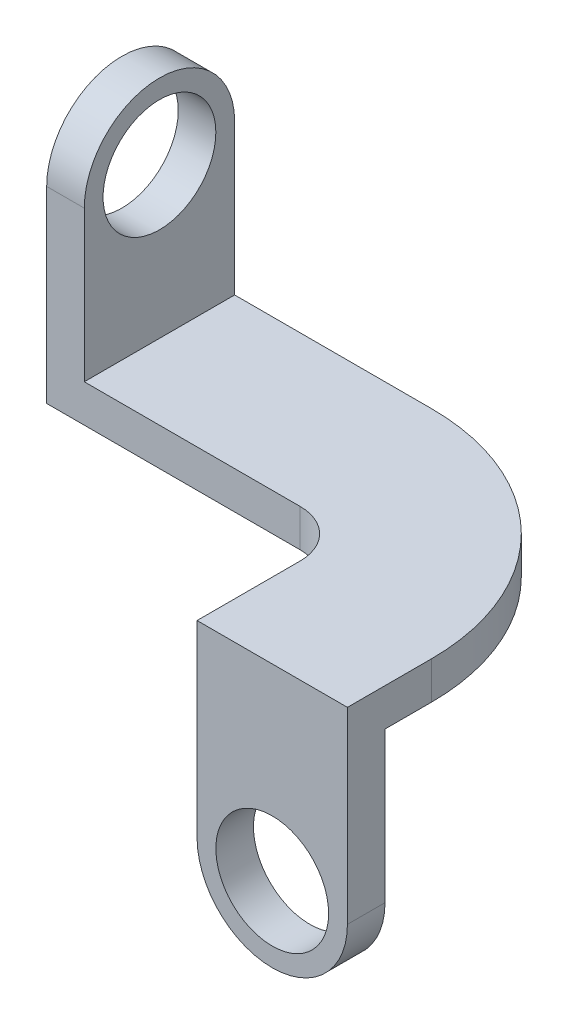
from build123d import *

# Parameters (mm, degrees)
SALIENTE_EXTRUIR1_DEPTH = 25.4
CROQUIS2_W              = 101.6
CROQUIS2_H              = 25.4
SALIENTE_EXTRUIR2_DEPTH = 101.6
CROQUIS3_R              = 50.8
SALIENTE_EXTRUIR3_DEPTH = 25.4
CROQUIS4_R              = 38.1
CORTAR_EXTRUIR1_DEPTH   = 204.2
CROQUIS5_W              = 25.4
CROQUIS5_H              = 101.6
SALIENTE_EXTRUIR4_DEPTH = 101.6
CROQUIS6_R              = 50.8
SALIENTE_EXTRUIR5_DEPTH = 25.4
CROQUIS7_R              = 38.1
CORTAR_EXTRUIR3_DEPTH   = 26.4


with BuildPart() as part:
    # Croquis1 → Saliente-Extruir1 (new body)
    with BuildSketch(Plane(origin=(0, 0, 0), x_dir=(1, 0, 0), z_dir=(0, 1, 0))):
        with BuildLine():
            Line((0, 0), (0, 101.6))
            Line((0, 101.6), (158.496, 101.6))
            ThreePointArc((158.496, 101.6), (261.948550515, 58.748550515), (304.8, -44.704))
            Line((304.8, -44.704), (304.8, -101.6))
            Line((304.8, -101.6), (203.2, -101.6))
            Line((203.2, -101.6), (203.2, -32.004))
            ThreePointArc((203.2, -32.004), (193.826245425, -9.373754575), (171.196, 0))
            Line((171.196, 0), (0, 0))
        make_face()
    extrude(amount=SALIENTE_EXTRUIR1_DEPTH)

    # Croquis2 → Saliente-Extruir2 (add)
    with BuildSketch(Plane.XZ):
        with Locations((254, 88.9)):
            Rectangle(CROQUIS2_W, CROQUIS2_H)
    extrude(amount=SALIENTE_EXTRUIR2_DEPTH)

    # Croquis3 → Saliente-Extruir3 (add)
    with BuildSketch(Plane.XY.offset(101.6)):
        with Locations((254, -101.6)):
            Circle(CROQUIS3_R)
    extrude(amount=-SALIENTE_EXTRUIR3_DEPTH)

    # Croquis4 → Cortar-Extruir1 (cut, through all)
    with BuildSketch(Plane.XY.offset(101.6)):
        with Locations((254, -101.6)):
            Circle(CROQUIS4_R)
    extrude(amount=-CORTAR_EXTRUIR1_DEPTH, mode=Mode.SUBTRACT)

    # Croquis5 → Saliente-Extruir4 (add)
    with BuildSketch(Plane(origin=(0, 25.4, 0), x_dir=(1, 0, 0), z_dir=(0, 1, 0))):
        with Locations((12.7, 50.8)):
            Rectangle(CROQUIS5_W, CROQUIS5_H)
    extrude(amount=SALIENTE_EXTRUIR4_DEPTH)

    # Croquis6 → Saliente-Extruir5 (add)
    with BuildSketch(Plane(origin=(25.4, 0, 0), x_dir=(0, 0, -1), z_dir=(1, 0, 0))):
        with Locations((50.8, 127)):
            Circle(CROQUIS6_R)
    extrude(amount=-SALIENTE_EXTRUIR5_DEPTH)

    # Croquis7 → Cortar-Extruir3 (cut, through all)
    with BuildSketch(Plane(origin=(25.4, 0, 0), x_dir=(0, 0, -1), z_dir=(1, 0, 0))):
        with Locations((50.8, 127)):
            Circle(CROQUIS7_R)
    extrude(amount=-CORTAR_EXTRUIR3_DEPTH, mode=Mode.SUBTRACT)


solid = part.part
